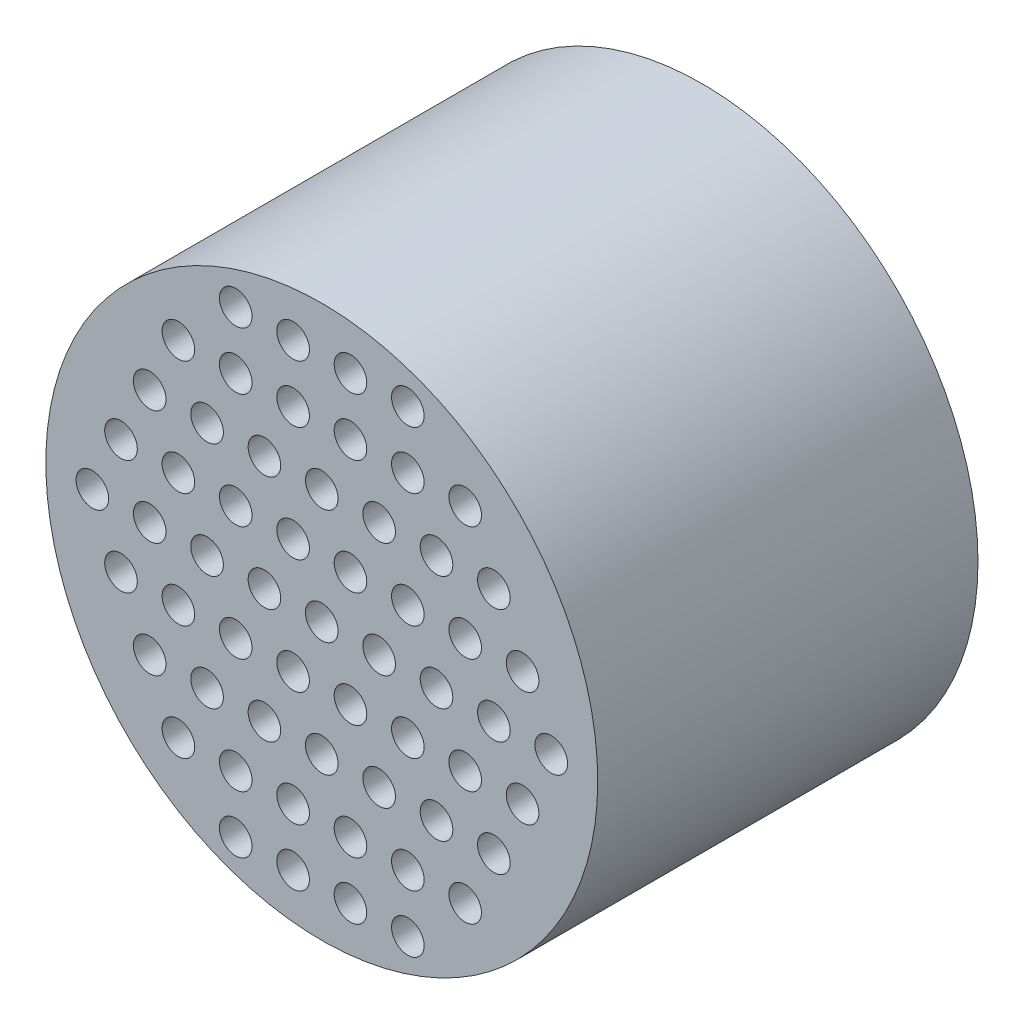
from build123d import *

# Parameters (mm, degrees)
ESQUISSE1_R             = 25.4
BOSS_EXTRU_1_DEPTH      = 25
ESQUISSE6_R             = 1.55
ENL_V_MAT_EXTRU_4_DEPTH = 6
ESQUISSE8_R             = 25.4
BOSS_EXTRU_3_DEPTH      = 10
ESQUISSE9_R             = 1.5
ENL_V_MAT_EXTRU_5_DEPTH = 10


with BuildPart() as part:
    # Esquisse1 → Boss.-Extru.1 (new body)
    with BuildSketch(Plane.XY):
        with Locations((16.625210007, 7.108710486)):
            Circle(ESQUISSE1_R)
    extrude(amount=BOSS_EXTRU_1_DEPTH)

    # Esquisse6 → Enlèv. mat.-Extru.4 (cut)
    with BuildSketch(Plane(origin=(0, 0, 0), x_dir=(-1, 0, 0), z_dir=(0, 0, -1))):
        with Locations((-39.525210007, 7.108710486)):
            Circle(ESQUISSE6_R)
        with Locations((6.274789993, 7.108710486)):
            Circle(ESQUISSE6_R)
    extrude(amount=-ENL_V_MAT_EXTRU_4_DEPTH, mode=Mode.SUBTRACT)

    # Esquisse8 → Boss.-Extru.3 (add)
    with BuildSketch(Plane.XY.offset(25)):
        with Locations((16.625210007, 7.108710486)):
            Circle(ESQUISSE8_R)
    extrude(amount=BOSS_EXTRU_3_DEPTH)

    # Esquisse9 → Enlèv. mat.-Extru.5 (cut)
    with BuildSketch(Plane.XY.offset(35)):
        with Locations((16.625210007, 7.108710486)):
            Circle(ESQUISSE9_R)
        with Locations((21.905210007, 7.108710486)):
            Circle(ESQUISSE9_R)
        with Locations((27.185210007, 7.108710486)):
            Circle(ESQUISSE9_R)
        with Locations((32.465210007, 7.108710486)):
            Circle(ESQUISSE9_R)
        with Locations((37.745210007, 7.108710486)):
            Circle(ESQUISSE9_R)
        with Locations((11.345210007, 7.108710486)):
            Circle(ESQUISSE9_R)
        with Locations((6.065210007, 7.108710486)):
            Circle(ESQUISSE9_R)
        with Locations((0.785210007, 7.108710486)):
            Circle(ESQUISSE9_R)
        with Locations((-4.494789993, 7.108710486)):
            Circle(ESQUISSE9_R)
        with Locations((0.785210007, 17.668710486)):
            Circle(ESQUISSE9_R)
        with Locations((6.065210007, 17.668710486)):
            Circle(ESQUISSE9_R)
        with Locations((11.345210007, 17.668710486)):
            Circle(ESQUISSE9_R)
        with Locations((16.625210007, 17.668710486)):
            Circle(ESQUISSE9_R)
        with Locations((21.905210007, 17.668710486)):
            Circle(ESQUISSE9_R)
        with Locations((27.185210007, 17.668710486)):
            Circle(ESQUISSE9_R)
        with Locations((32.465210007, 17.668710486)):
            Circle(ESQUISSE9_R)
        with Locations((8.705210007, 12.388710486)):
            Circle(ESQUISSE9_R)
        with Locations((13.985210007, 12.388710486)):
            Circle(ESQUISSE9_R)
        with Locations((19.265210007, 12.388710486)):
            Circle(ESQUISSE9_R)
        with Locations((24.545210007, 12.388710486)):
            Circle(ESQUISSE9_R)
        with Locations((29.825210007, 12.388710486)):
            Circle(ESQUISSE9_R)
        with Locations((35.105210007, 12.388710486)):
            Circle(ESQUISSE9_R)
        with Locations((3.425210007, 12.388710486)):
            Circle(ESQUISSE9_R)
        with Locations((-1.854789993, 12.388710486)):
            Circle(ESQUISSE9_R)
        with Locations((13.985210007, 22.948710486)):
            Circle(ESQUISSE9_R)
        with Locations((19.265210007, 22.948710486)):
            Circle(ESQUISSE9_R)
        with Locations((24.545210007, 22.948710486)):
            Circle(ESQUISSE9_R)
        with Locations((13.985210007, 28.228710486)):
            Circle(ESQUISSE9_R)
        with Locations((19.265210007, 28.228710486)):
            Circle(ESQUISSE9_R)
        with Locations((24.545210007, 28.228710486)):
            Circle(ESQUISSE9_R)
        with Locations((8.705210007, 22.948710486)):
            Circle(ESQUISSE9_R)
        with Locations((8.705210007, 28.228710486)):
            Circle(ESQUISSE9_R)
        with Locations((29.825210007, 22.948710486)):
            Circle(ESQUISSE9_R)
        with Locations((3.425210007, 22.948710486)):
            Circle(ESQUISSE9_R)
        with Locations((35.105210007, 1.828710486)):
            Circle(ESQUISSE9_R)
        with Locations((29.825210007, 1.828710486)):
            Circle(ESQUISSE9_R)
        with Locations((24.545210007, 1.828710486)):
            Circle(ESQUISSE9_R)
        with Locations((19.265210007, 1.828710486)):
            Circle(ESQUISSE9_R)
        with Locations((13.985210007, 1.828710486)):
            Circle(ESQUISSE9_R)
        with Locations((8.705210007, 1.828710486)):
            Circle(ESQUISSE9_R)
        with Locations((3.425210007, 1.828710486)):
            Circle(ESQUISSE9_R)
        with Locations((-1.854789993, 1.828710486)):
            Circle(ESQUISSE9_R)
        with Locations((0.785210007, -3.451289514)):
            Circle(ESQUISSE9_R)
        with Locations((6.065210007, -3.451289514)):
            Circle(ESQUISSE9_R)
        with Locations((11.345210007, -3.451289514)):
            Circle(ESQUISSE9_R)
        with Locations((16.625210007, -3.451289514)):
            Circle(ESQUISSE9_R)
        with Locations((21.905210007, -3.451289514)):
            Circle(ESQUISSE9_R)
        with Locations((27.185210007, -3.451289514)):
            Circle(ESQUISSE9_R)
        with Locations((32.465210007, -3.451289514)):
            Circle(ESQUISSE9_R)
        with Locations((29.825210007, -8.731289514)):
            Circle(ESQUISSE9_R)
        with Locations((24.545210007, -8.731289514)):
            Circle(ESQUISSE9_R)
        with Locations((19.265210007, -8.731289514)):
            Circle(ESQUISSE9_R)
        with Locations((13.985210007, -8.731289514)):
            Circle(ESQUISSE9_R)
        with Locations((8.705210007, -8.731289514)):
            Circle(ESQUISSE9_R)
        with Locations((3.425210007, -8.731289514)):
            Circle(ESQUISSE9_R)
        with Locations((8.705210007, -14.011289514)):
            Circle(ESQUISSE9_R)
        with Locations((13.985210007, -14.011289514)):
            Circle(ESQUISSE9_R)
        with Locations((19.265210007, -14.011289514)):
            Circle(ESQUISSE9_R)
        with Locations((24.545210007, -14.011289514)):
            Circle(ESQUISSE9_R)
    extrude(amount=-ENL_V_MAT_EXTRU_5_DEPTH, mode=Mode.SUBTRACT)

    # Esquisse12 → Enlèvement de matière-Révolution1 (revolve, cut)
    with BuildSketch(Plane(origin=(16.625210007, 0, 0), x_dir=(0, 0, -1), z_dir=(1, 0, 0))):
        Polygon((0, 7.108710486), (0, 27.108710486), (-25, 30.108710486), (-25, 7.108710486), align=None)
    revolve(axis=Axis((16.625210007, 7.108710486, 25), (0, 0, -1)), mode=Mode.SUBTRACT)


solid = part.part
